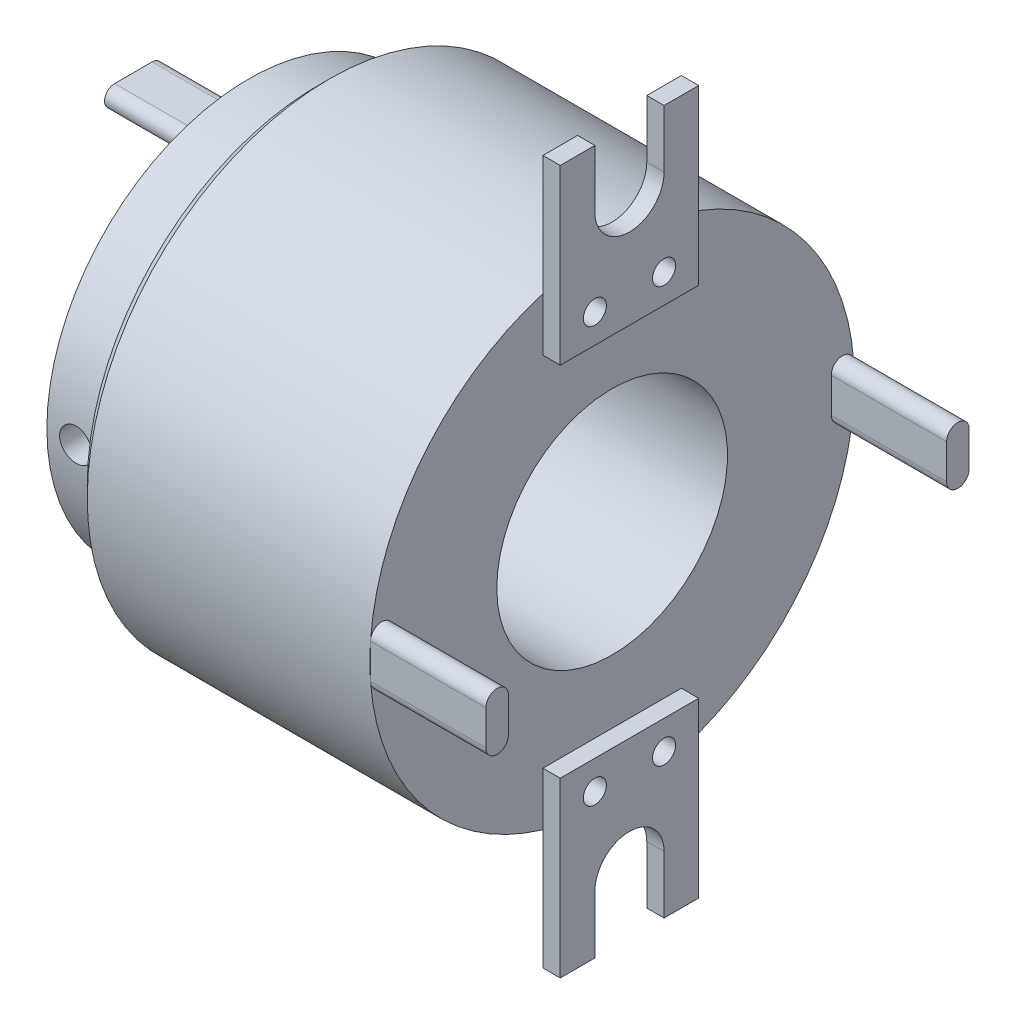
from build123d import *

# Parameters (mm, degrees)
SKETCH2_R           = 1.4
CUT_EXTRUDE1_DEPTH  = 10
CIRPATTERN1_COUNT   = 2
CHAMFER1_SIZE       = 1
BOSS_EXTRUDE1_DEPTH = 10
BOSS_EXTRUDE2_DEPTH = 10
SKETCH7_R           = 1
BOSS_EXTRUDE3_DEPTH = 1.5
CIRPATTERN2_COUNT   = 2


with BuildPart() as part:
    # Sketch1 → Revolve1 (revolve)
    with BuildSketch(Plane.XY, mode=Mode.PRIVATE) as revolve1_sk:
        Polygon((-13.027559055, 10), (18.472440945, 10), (18.472440945, 21), (-7.027559055, 21), (-7.027559055, 15.5), (-8.027559055, 15.5), (-8.027559055, 17.5), (-13.027559055, 17.5), align=None)
    revolve(revolve1_sk.sketch.rotate(Axis((-13.027559055, 0, 0), (1, 0, 0)), 90), axis=Axis((-13.027559055, 0, 0), (1, 0, 0)))

    # Sketch2 → Cut-Extrude1 (cut)
    with BuildSketch(Plane.XY.offset(17.5)):
        with Locations((-10.527559055, 0)):
            Circle(SKETCH2_R)
    cut_extrude1 = extrude(amount=-CUT_EXTRUDE1_DEPTH, mode=Mode.SUBTRACT)

    # CirPattern1: Cut-Extrude1 ×2 about axis
    cirpattern1_axis = Axis((-13.027559055, 0, 0), (-1, 0, 0))
    for i in range(1, CIRPATTERN1_COUNT):
        add(cut_extrude1.rotate(cirpattern1_axis, i * 360 / CIRPATTERN1_COUNT), mode=Mode.SUBTRACT)

    # Chamfer1
    chamfer1_edges = [part.edges().sort_by_distance(p)[0] for p in [
        (-7.027559055, 0, -21),
    ]]
    chamfer(chamfer1_edges, length=CHAMFER1_SIZE)

    # Sketch5 → Boss-Extrude1 (add)
    with BuildSketch(Plane.ZY.offset(13.027559055)):
        with BuildLine():
            Line((-1.622283046, 12.958236181), (1.622283046, 12.958236181))
            ThreePointArc((1.622283046, 12.958236181), (2.503523219, 12.076996008), (1.622283046, 11.195755835))
            Line((1.622283046, 11.195755835), (-1.622283046, 11.195755835))
            ThreePointArc((-1.622283046, 11.195755835), (-2.503523219, 12.076996008), (-1.622283046, 12.958236181))
        make_face()
        with BuildLine():
            Line((1.622283046, -12.958236181), (-1.622283046, -12.958236181))
            ThreePointArc((-1.622283046, -12.958236181), (-2.503523219, -12.076996008), (-1.622283046, -11.195755835))
            Line((-1.622283046, -11.195755835), (1.622283046, -11.195755835))
            ThreePointArc((1.622283046, -11.195755835), (2.503523219, -12.076996008), (1.622283046, -12.958236181))
        make_face()
    extrude(amount=BOSS_EXTRUDE1_DEPTH)

    # Sketch6 → Boss-Extrude2 (add)
    with BuildSketch(Plane(origin=(18.472440945, 0, 0), x_dir=(0, 0, -1), z_dir=(1, 0, 0))):
        with BuildLine():
            Line((-20.943347365, -1.505224441), (-20.943347365, 1.505224441))
            ThreePointArc((-20.943347365, 1.505224441), (-19.968101194, 2.480470612), (-18.992855023, 1.505224441))
            Line((-18.992855023, 1.505224441), (-18.992855023, -1.505224441))
            ThreePointArc((-18.992855023, -1.505224441), (-19.968101194, -2.480470612), (-20.943347365, -1.505224441))
        make_face()
        with BuildLine():
            Line((18.992855023, 1.505224441), (18.992855023, -1.505224441))
            ThreePointArc((18.992855023, -1.505224441), (19.968101194, -2.480470612), (20.943347365, -1.505224441))
            Line((20.943347365, -1.505224441), (20.943347365, 1.505224441))
            ThreePointArc((20.943347365, 1.505224441), (19.968101194, 2.480470612), (18.992855023, 1.505224441))
        make_face()
    extrude(amount=BOSS_EXTRUDE2_DEPTH)

    # Sketch7 → Boss-Extrude3 (add)
    with BuildSketch(Plane(origin=(18.472440945, 0, 0), x_dir=(0, 0, -1), z_dir=(1, 0, 0))):
        with BuildLine():
            Line((-6, 30.5), (-3, 30.5))
            Line((-3, 30.5), (-3, 25.5))
            ThreePointArc((-3, 25.5), (0, 22.5), (3, 25.5))
            Line((3, 25.5), (3, 30.5))
            Line((3, 30.5), (6, 30.5))
            Line((6, 30.5), (6, 15.5))
            Line((6, 15.5), (-6, 15.5))
            Line((-6, 15.5), (-6, 30.5))
        make_face()
        with Locations((-3, 18)):
            Circle(SKETCH7_R, mode=Mode.SUBTRACT)
        with Locations((3, 18)):
            Circle(SKETCH7_R, mode=Mode.SUBTRACT)
    boss_extrude3 = extrude(amount=BOSS_EXTRUDE3_DEPTH)

    # CirPattern2: Boss-Extrude3 ×2 about axis
    cirpattern2_axis = Axis((0, 0, 0), (1, 0, 0))
    for i in range(1, CIRPATTERN2_COUNT):
        add(boss_extrude3.rotate(cirpattern2_axis, i * 360 / CIRPATTERN2_COUNT))


solid = part.part
